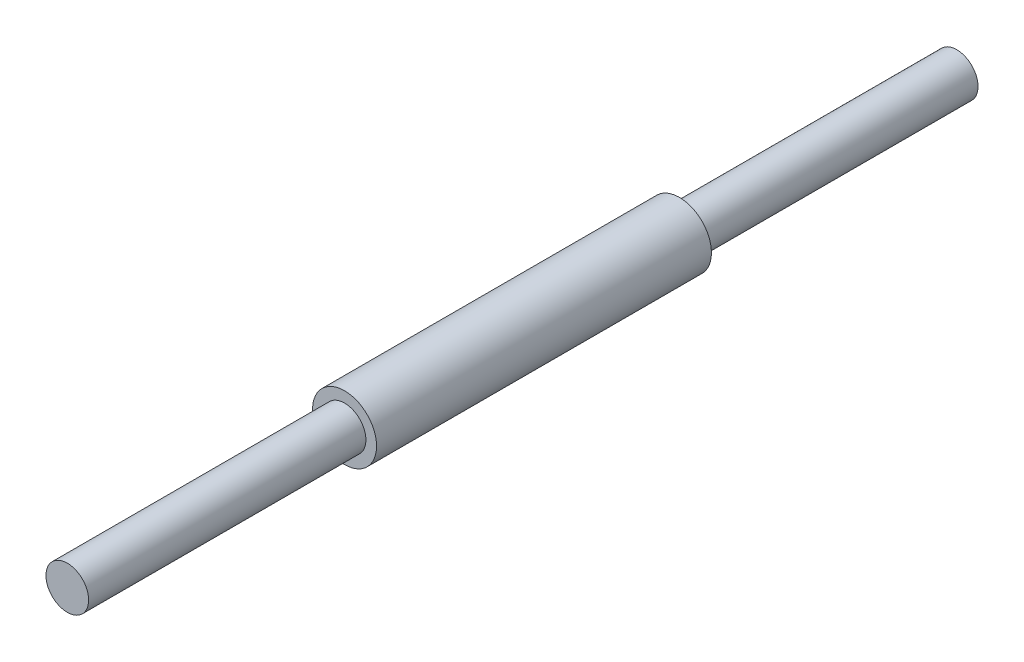
from build123d import *

# Parameters (mm, degrees)
SKETCH1_R           = 3.81
BOSS_EXTRUDE1_DEPTH = 39.878
SKETCH2_R           = 2.54
BOSS_EXTRUDE2_DEPTH = 33.02
SKETCH3_R           = 2.54
BOSS_EXTRUDE3_DEPTH = 33.02


with BuildPart() as part:
    # Sketch1 → Boss-Extrude1 (new body)
    with BuildSketch(Plane.XY):
        Circle(SKETCH1_R)
    extrude(amount=BOSS_EXTRUDE1_DEPTH)

    # Sketch2 → Boss-Extrude2 (add)
    with BuildSketch(Plane.XY.offset(39.878)):
        Circle(SKETCH2_R)
    extrude(amount=BOSS_EXTRUDE2_DEPTH)

    # Sketch3 → Boss-Extrude3 (add)
    with BuildSketch(Plane(origin=(0, 0, 0), x_dir=(-1, 0, 0), z_dir=(0, 0, -1))):
        Circle(SKETCH3_R)
    extrude(amount=BOSS_EXTRUDE3_DEPTH)


solid = part.part
